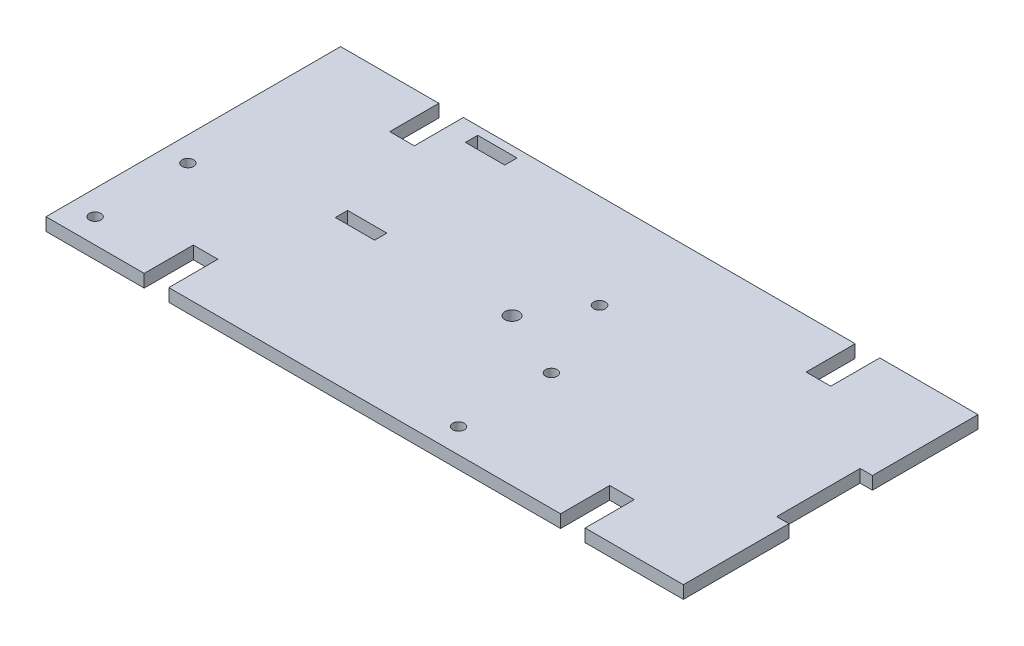
from build123d import *

# Parameters (mm, degrees)
SKETCH1_R           = 1.8288
BOSS_EXTRUDE1_DEPTH = 3.302
SKETCH2_R           = 1.5
CUT_EXTRUDE1_DEPTH  = 4.302
SKETCH3_R           = 1.524
SKETCH3_W           = 10.16
SKETCH3_H           = 3.175
CUT_EXTRUDE2_DEPTH  = 4.302


with BuildPart() as part:
    # Sketch1 → Boss-Extrude1 (new body)
    with BuildSketch(Plane(origin=(0, 0, 0), x_dir=(1, 0, 0), z_dir=(0, 1, 0))):
        Polygon((-164.846, 76.2), (-139.446, 76.2), (-139.446, 63.5), (-133.096, 63.5), (-133.096, 76.2), (-31.75, 76.2), (-31.75, 63.5), (-25.4, 63.5), (-25.4, 76.2), (0, 76.2), (0, 48.895), (-3.175, 48.895), (-3.175, 27.305), (0, 27.305), (0, 0), (-25.4, 0), (-25.4, 12.7), (-31.75, 12.7), (-31.75, 0), (-133.096, 0), (-133.096, 12.7), (-139.446, 12.7), (-139.446, 0), (-164.846, 0), (-164.846, 27.305), (-164.846, 48.895), align=None)
        with Locations((-82.423, 38.1)):
            Circle(SKETCH1_R, mode=Mode.SUBTRACT)
    extrude(amount=BOSS_EXTRUDE1_DEPTH)

    # Sketch2 → Cut-Extrude1 (cut, through all)
    with BuildSketch(Plane(origin=(0, 3.302, 0), x_dir=(1, 0, 0), z_dir=(0, 1, 0))):
        with Locations((-158.496, 30.35)):
            Circle(SKETCH2_R)
        with Locations((-158.496, 6.35)):
            Circle(SKETCH2_R)
        with Locations((-64.496, 6.35)):
            Circle(SKETCH2_R)
        with Locations((-64.496, 30.35)):
            Circle(SKETCH2_R)
    extrude(amount=-CUT_EXTRUDE1_DEPTH, mode=Mode.SUBTRACT)

    # Sketch3 → Cut-Extrude2 (cut, through all)
    with BuildSketch(Plane(origin=(0, 3.302, 0), x_dir=(1, 0, 0), z_dir=(0, 1, 0))):
        with Locations((-73.406, 51.723686304)):
            Circle(SKETCH3_R)
        with Locations((-122.169322677, 38.81724188)):
            Rectangle(SKETCH3_W, SKETCH3_H)
        with Locations((-122.169322677, 72.47224188)):
            Rectangle(SKETCH3_W, SKETCH3_H)
    extrude(amount=-CUT_EXTRUDE2_DEPTH, mode=Mode.SUBTRACT)


solid = part.part
